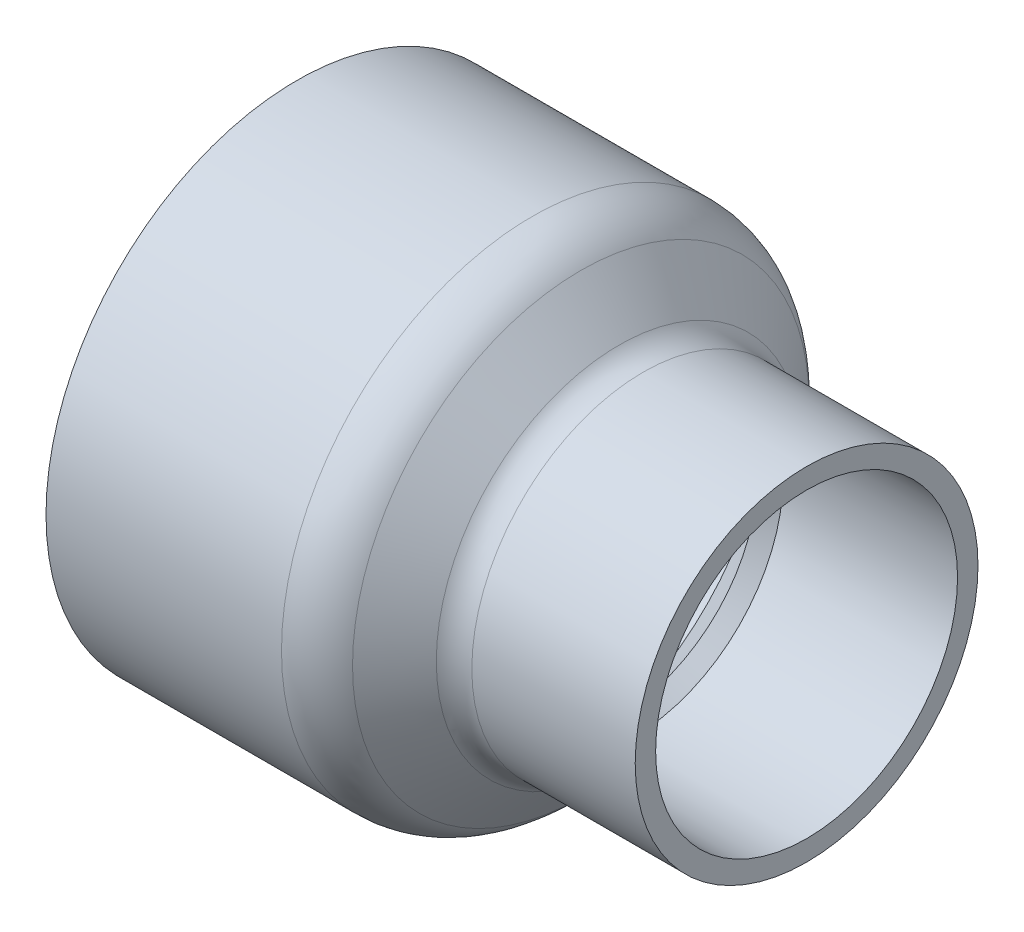
from build123d import *

# Parameters (mm, degrees)
FILLET1_R = 12.7
FILLET2_R = 6.35


with BuildPart() as part:
    # Sketch1 → Revolve1 (revolve)
    with BuildSketch(Plane.XY):
        Polygon((-0.381, -44.3484), (13.568194302, -27.724397577), (16.383, -30.0863), (51.181, -30.3149), (51.181, -34.417), (15.412836736, -34.417), (2.028190699, -50.3682), (-51.181, -50.3682), (-51.181, -44.6532), align=None)
    revolve(axis=Axis((-51.181, 0, 0), (1, 0, 0)))

    # Fillet1
    fillet1_edges = [part.edges().sort_by_distance(p)[0] for p in [
        (2.028190699, 50.3682, 0),
    ]]
    fillet(fillet1_edges, radius=FILLET1_R)

    # Fillet2
    fillet2_edges = [part.edges().sort_by_distance(p)[0] for p in [
        (15.412836736, 34.417, 0),
    ]]
    fillet(fillet2_edges, radius=FILLET2_R)


solid = part.part
